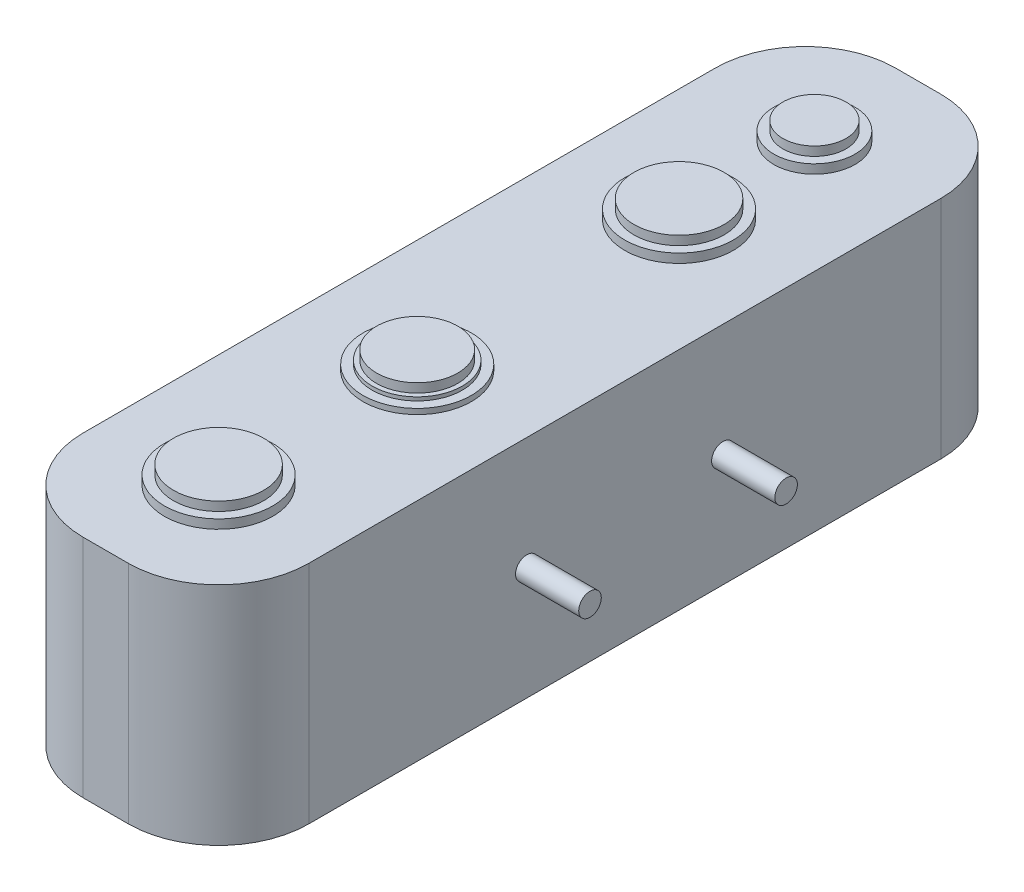
from build123d import *

# Parameters (mm, degrees)
SKETCH1_W           = 25
SKETCH1_H           = 90
BOSS_EXTRUDE1_DEPTH = 25
SKETCH2_R           = 5
SKETCH2_R_2         = 3.5
SKETCH2_R_3         = 4.5
BOSS_EXTRUDE2_DEPTH = 2
SKETCH2_3_R         = 6
SKETCH2_3_R_2       = 4.5
SKETCH2_3_R_3       = 5
BOSS_EXTRUDE3_DEPTH = 1
SKETCH2_4_R         = 6
BOSS_EXTRUDE4_DEPTH = 0.6
FILLET1_R           = 10
SKETCH3_R           = 1.25
BOSS_EXTRUDE5_DEPTH = 7


with BuildPart() as part:
    # Sketch1 → Boss-Extrude1 (new body)
    with BuildSketch(Plane(origin=(0, 0, 0), x_dir=(1, 0, 0), z_dir=(0, 1, 0))):
        Rectangle(SKETCH1_W, SKETCH1_H)
    extrude(amount=BOSS_EXTRUDE1_DEPTH)

    # Sketch2 → Boss-Extrude2 (add)
    with BuildSketch(Plane(origin=(0, 25, 0), x_dir=(1, 0, 0), z_dir=(0, 1, 0))):
        with Locations((0, -32.5)):
            Circle(SKETCH2_R)
        with Locations((0, 18.5)):
            Circle(SKETCH2_R)
        with Locations((0, 33.5)):
            Circle(SKETCH2_R_2)
        with Locations((0, -10.5)):
            Circle(SKETCH2_R_3)
    extrude(amount=BOSS_EXTRUDE2_DEPTH)

    # Sketch2_3 → Boss-Extrude3 (add)
    with BuildSketch(Plane(origin=(0, 25, 0), x_dir=(1, 0, 0), z_dir=(0, 1, 0))):
        with Locations((0, -32.5)):
            Circle(SKETCH2_3_R)
        with Locations((0, 18.5)):
            Circle(SKETCH2_3_R)
        with Locations((0, 33.5)):
            Circle(SKETCH2_3_R_2)
        with Locations((0, -10.5)):
            Circle(SKETCH2_3_R_3)
    extrude(amount=BOSS_EXTRUDE3_DEPTH)

    # Sketch2_4 → Boss-Extrude4 (add)
    with BuildSketch(Plane(origin=(0, 25, 0), x_dir=(1, 0, 0), z_dir=(0, 1, 0))):
        with Locations((0, -10.5)):
            Circle(SKETCH2_4_R)
    extrude(amount=BOSS_EXTRUDE4_DEPTH)

    # Fillet1
    fillet1_edges = [part.edges().sort_by_distance(p)[0] for p in [
        (-12.5, 12.5, 45),
        (12.5, 12.5, 45),
        (12.5, 12.5, -45),
        (-12.5, 12.5, -45),
    ]]
    fillet(fillet1_edges, radius=FILLET1_R)

    # Sketch3 → Boss-Extrude5 (add)
    with BuildSketch(Plane(origin=(12.5, 0, 0), x_dir=(0, 0, -1), z_dir=(1, 0, 0))):
        with Locations((-10.86, 12.5)):
            Circle(SKETCH3_R)
        with Locations((10.86, 12.5)):
            Circle(SKETCH3_R)
    extrude(amount=BOSS_EXTRUDE5_DEPTH)


solid = part.part
